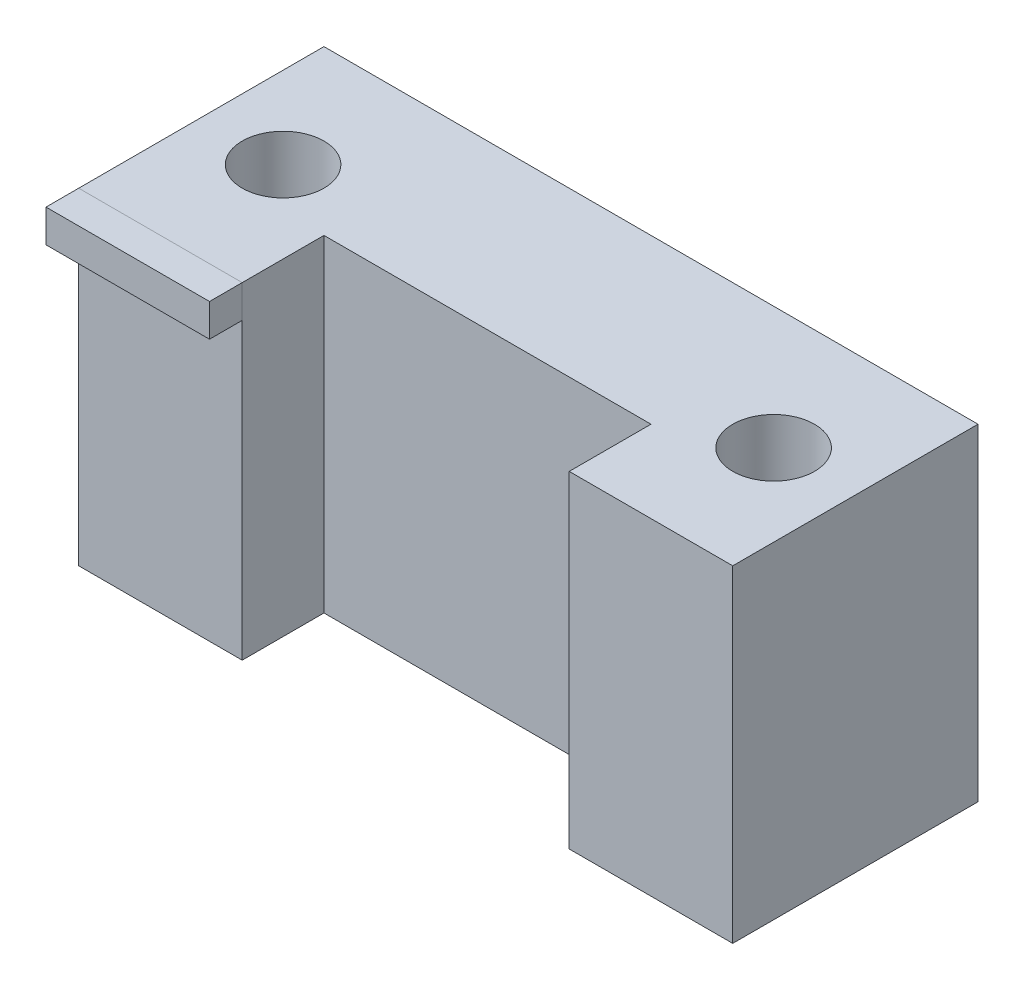
from build123d import *

# Parameters (mm, degrees)
BOSS_EXTRUDE1_DEPTH = 100
HOLE1_D             = 25
SKETCH3_W           = 50
SKETCH3_H           = 10
BOSS_EXTRUDE2_DEPTH = 10


with BuildPart() as part:
    # Sketch1 → Boss-Extrude1 (new body)
    with BuildSketch(Plane(origin=(0, 0, 0), x_dir=(1, 0, 0), z_dir=(0, 1, 0))):
        Polygon((150, 0), (200, 0), (200, 75), (0, 75), (0, 0), (50, 0), (50, 25), (150, 25), align=None)
    extrude(amount=BOSS_EXTRUDE1_DEPTH)

    # Hole1 (through all)
    with Locations(Plane(origin=(175, 0, -37.5), x_dir=(0, 0, -1), z_dir=(0, -1, 0))):
        with Locations((0, 0), (0, -150)):
            Hole(HOLE1_D / 2)


with BuildPart() as body_2:
    # Sketch3 → Boss-Extrude2 (new body)
    with BuildSketch(Plane.XY):
        with Locations((25, 95)):
            Rectangle(SKETCH3_W, SKETCH3_H)
    extrude(amount=BOSS_EXTRUDE2_DEPTH)


solid = Compound([part.part, body_2.part])
